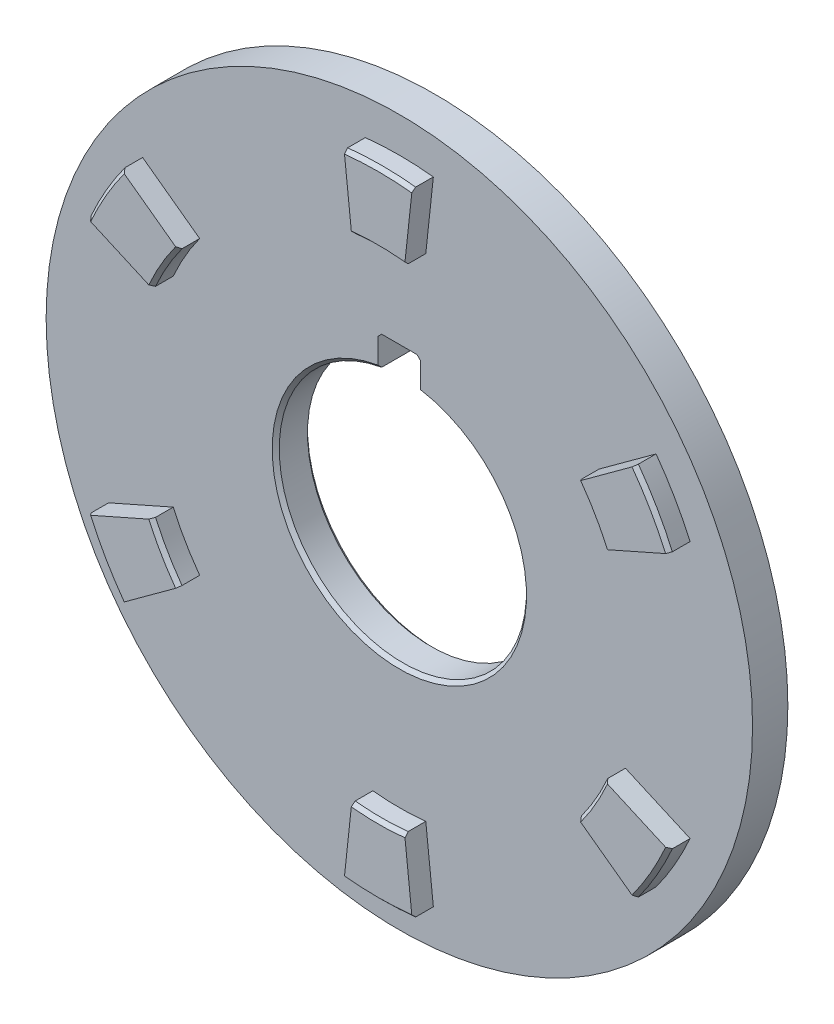
from build123d import *

# Parameters (mm, degrees)
SKETCH1_R                = 100
BOSS_EXTRUDE1_DEPTH      = 5
CUT_EXTRUDE1_DEPTH       = 11
BOSS_EXTRUDE3_DEPTH      = 6
CHAMFER1_SIZE            = 1
CHAMFER2_SIZE            = 1
CHAMFER3_SIZE            = 1
CHAMFER1_OF_MIRROR1_SIZE = 1


with BuildPart() as part:
    # Sketch1 → Boss-Extrude1 (new body, symmetric)
    with BuildSketch(Plane.XY):
        Circle(SKETCH1_R)
    extrude(amount=BOSS_EXTRUDE1_DEPTH, both=True)

    # Sketch2 → Cut-Extrude1 (cut, through all)
    with BuildSketch(Plane.XY.offset(5)):
        with BuildLine():
            Line((6, 34.481879299), (6, 43.6))
            Line((6, 43.6), (-6, 43.6))
            Line((-6, 43.6), (-6, 34.481879299))
            ThreePointArc((-6, 34.481879299), (0, -35), (6, 34.481879299))
        make_face()
    extrude(amount=-CUT_EXTRUDE1_DEPTH, mode=Mode.SUBTRACT)

    # Sketch3 → Boss-Extrude3 (add)
    with BuildSketch(Plane.XY.offset(5)):
        with BuildLine():
            ThreePointArc((-7.489441028, 69.598191593), (0, 70), (7.489441028, 69.598191593))
            Line((7.489441028, 69.598191593), (9.629281322, 89.483389192))
            ThreePointArc((9.629281322, 89.483389192), (0, 90), (-9.629281322, 89.483389192))
            Line((-9.629281322, 89.483389192), (-7.489441028, 69.598191593))
        make_face()
        with BuildLine():
            ThreePointArc((-64.018522492, 28.313049606), (-60.621778265, 35), (-56.529081463, 41.285141987))
            Line((-56.529081463, 41.285141987), (-72.680247596, 53.080896841))
            ThreePointArc((-72.680247596, 53.080896841), (-77.942286341, 45), (-82.309528918, 36.402492351))
            Line((-82.309528918, 36.402492351), (-64.018522492, 28.313049606))
        make_face()
        with BuildLine():
            ThreePointArc((-56.529081463, -41.285141987), (-60.621778265, -35), (-64.018522492, -28.313049606))
            Line((-64.018522492, -28.313049606), (-82.309528918, -36.402492351))
            ThreePointArc((-82.309528918, -36.402492351), (-77.942286341, -45), (-72.680247596, -53.080896841))
            Line((-72.680247596, -53.080896841), (-56.529081463, -41.285141987))
        make_face()
        with BuildLine():
            ThreePointArc((7.489441028, -69.598191593), (0, -70), (-7.489441028, -69.598191593))
            Line((-7.489441028, -69.598191593), (-9.629281322, -89.483389192))
            ThreePointArc((-9.629281322, -89.483389192), (0, -90), (9.629281322, -89.483389192))
            Line((9.629281322, -89.483389192), (7.489441028, -69.598191593))
        make_face()
        with BuildLine():
            ThreePointArc((64.018522492, -28.313049606), (60.621778265, -35), (56.529081463, -41.285141987))
            Line((56.529081463, -41.285141987), (72.680247596, -53.080896841))
            ThreePointArc((72.680247596, -53.080896841), (77.942286341, -45), (82.309528918, -36.402492351))
            Line((82.309528918, -36.402492351), (64.018522492, -28.313049606))
        make_face()
        with BuildLine():
            ThreePointArc((56.529081463, 41.285141987), (60.621778265, 35), (64.018522492, 28.313049606))
            Line((64.018522492, 28.313049606), (82.309528918, 36.402492351))
            ThreePointArc((82.309528918, 36.402492351), (77.942286341, 45), (72.680247596, 53.080896841))
            Line((72.680247596, 53.080896841), (56.529081463, 41.285141987))
        make_face()
    boss_extrude3 = extrude(amount=BOSS_EXTRUDE3_DEPTH)

    # Chamfer1
    chamfer1_edges = [part.edges().sort_by_distance(p)[0] for p in [
        (0, 70, 11),
        (0, 90, 11),
        (-60.621778265, 35, 11),
        (-77.942286341, 45, 11),
        (-60.621778265, -35, 11),
        (-77.942286341, -45, 11),
        (0, -70, 11),
        (0, -90, 11),
        (60.621778265, -35, 11),
        (77.942286341, -45, 11),
        (60.621778265, 35, 11),
        (77.942286341, 45, 11),
    ]]
    chamfer(chamfer1_edges, length=CHAMFER1_SIZE)

    # Chamfer2
    chamfer2_edges = [part.edges().sort_by_distance(p)[0] for p in [
        (0, -35, -5),
        (0, -35, 5),
    ]]
    chamfer(chamfer2_edges, length=CHAMFER2_SIZE)

    # Chamfer3
    chamfer3_edges = [part.edges().sort_by_distance(p)[0] for p in [
        (-6, 43.6, 0),
        (6, 43.6, 0),
    ]]
    chamfer(chamfer3_edges, length=CHAMFER3_SIZE)

    # Mirror1: Boss-Extrude3 across plane
    add(boss_extrude3.mirror(Plane.XY))

    # Chamfer1 of Mirror1
    chamfer1_of_mirror1_edges = [part.edges().sort_by_distance(p)[0] for p in [
        (0, 70, -11),
        (0, 90, -11),
        (-60.621778265, 35, -11),
        (-77.942286341, 45, -11),
        (-60.621778265, -35, -11),
        (-77.942286341, -45, -11),
        (0, -70, -11),
        (0, -90, -11),
        (60.621778265, -35, -11),
        (77.942286341, -45, -11),
        (60.621778265, 35, -11),
        (77.942286341, 45, -11),
    ]]
    chamfer(chamfer1_of_mirror1_edges, length=CHAMFER1_OF_MIRROR1_SIZE)


solid = part.part
